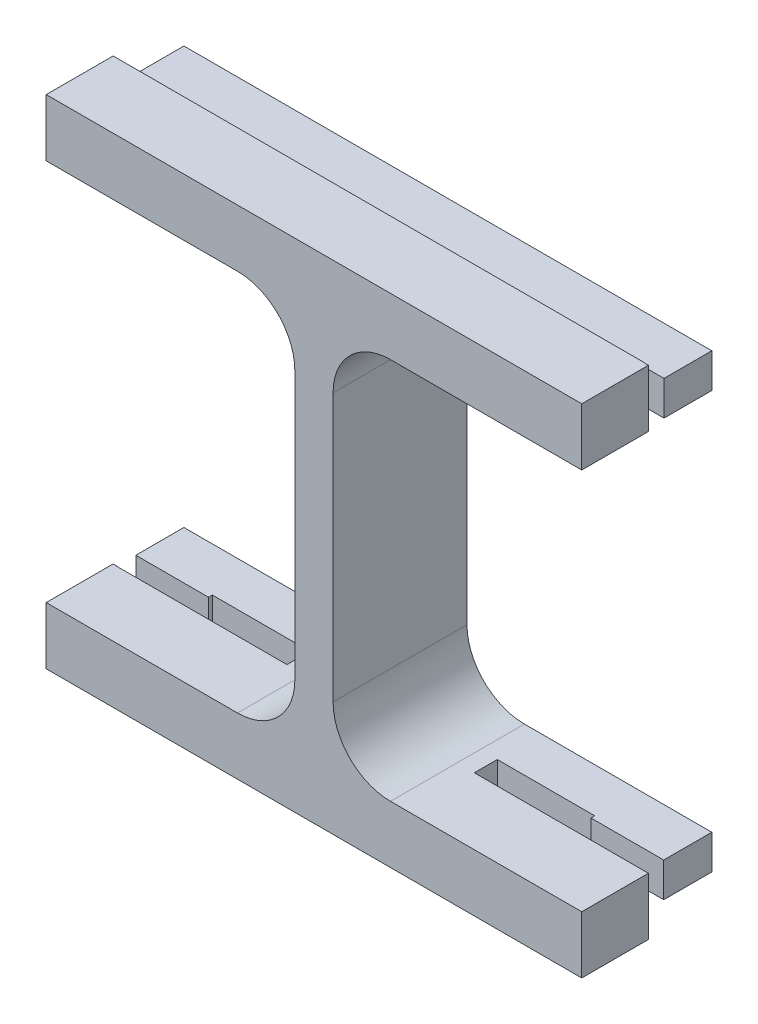
from build123d import *

# Parameters (mm, degrees)
SKETCH1_W           = 30
SKETCH1_H           = 22
BOSS_EXTRUDE1_DEPTH = 2
SKETCH2_W           = 13
SKETCH2_H           = 20
CUT_EXTRUDE1_DEPTH  = 2
FILLET1_R           = 3
SKETCH3_W           = 30
SKETCH3_H           = 22
BOSS_EXTRUDE2_DEPTH = 20
SKETCH4_W           = 30
SKETCH4_H           = 22
BOSS_EXTRUDE3_DEPTH = 2
SKETCH5_W           = 30
SKETCH5_H           = 22
BOSS_EXTRUDE4_DEPTH = 2
SKETCH6_W           = 18.015144258
SKETCH6_H           = 26
CUT_EXTRUDE2_DEPTH  = 1.2
SKETCH7_W           = 18
SKETCH7_H           = 26
CUT_EXTRUDE3_DEPTH  = 1.2
SKETCH8_W           = 27.6
SKETCH8_H           = 18
CUT_EXTRUDE4_DEPTH  = 1.2
SKETCH9_W           = 27.6
SKETCH9_H           = 18.015144258
CUT_EXTRUDE5_DEPTH  = 1.2
SKETCH10_W          = 8.9
SKETCH10_H          = 1
CUT_EXTRUDE7_DEPTH  = 1.8
SKETCH12_W          = 5.2
SKETCH12_H          = 1.2
CUT_EXTRUDE8_DEPTH  = 1.8
CUT_EXTRUDE9_DEPTH  = 3.2
SKETCH14_W          = 2.8
SKETCH14_H          = 1
CUT_EXTRUDE10_DEPTH = 5
SKETCH15_W          = 8.9
SKETCH15_H          = 1
CUT_EXTRUDE11_DEPTH = 5
SKETCH16_W          = 5.1
SKETCH16_H          = 1.2
CUT_EXTRUDE12_DEPTH = 5
SKETCH17_W          = 27.6
SKETCH17_H          = 14.5
CUT_EXTRUDE13_DEPTH = 23.6
CUT_EXTRUDE14_DEPTH = 5
SKETCH19_W          = 2.8
SKETCH19_H          = 20
CUT_EXTRUDE16_DEPTH = 3.5
SKETCH20_W          = 8.574892863
SKETCH20_H          = 20
SKETCH20_W_2        = 12.614156469
CUT_EXTRUDE18_DEPTH = 5
SKETCH24_W          = 0.5
SKETCH24_H          = 26
CUT_EXTRUDE19_DEPTH = 100
SKETCH25_W          = 4.142834468
SKETCH25_H          = 28.533772401
SKETCH25_W_2        = 4.453547053
SKETCH25_H_2        = 29.155197571
CUT_EXTRUDE20_DEPTH = 3.5


with BuildPart() as part:
    # Sketch1 → Boss-Extrude1 (new body)
    with BuildSketch(Plane.XY):
        with Locations((1.554069904, 0.785714286)):
            Rectangle(SKETCH1_W, SKETCH1_H)
    extrude(amount=BOSS_EXTRUDE1_DEPTH)

    # Sketch2 → Cut-Extrude1 (cut)
    with BuildSketch(Plane.XY.offset(2)):
        with Locations((-5.945930096, 0.785714286)):
            Rectangle(SKETCH2_W, SKETCH2_H)
        with Locations((9.054069904, 0.785714286)):
            Rectangle(SKETCH2_W, SKETCH2_H)
    extrude(amount=-CUT_EXTRUDE1_DEPTH, mode=Mode.SUBTRACT)

    # Fillet1
    fillet1_edges = [part.edges().sort_by_distance(p)[0] for p in [
        (-12.445930096, -9.214285714, 1),
        (-12.445930096, 10.785714286, 1),
        (0.554069904, 10.785714286, 1),
        (0.554069904, -9.214285714, 1),
        (15.554069904, 10.785714286, 1),
        (15.554069904, -9.214285714, 1),
        (2.554069904, -9.214285714, 1),
        (2.554069904, 10.785714286, 1),
    ]]
    fillet(fillet1_edges, radius=FILLET1_R)

    # Sketch3 → Boss-Extrude2 (add)
    with BuildSketch(Plane(origin=(0, 0, 0), x_dir=(-1, 0, 0), z_dir=(0, 0, -1))):
        with Locations((-1.554069904, 0.785714286)):
            Rectangle(SKETCH3_W, SKETCH3_H)
    extrude(amount=BOSS_EXTRUDE2_DEPTH)

    # Sketch4 → Boss-Extrude3 (add)
    with BuildSketch(Plane(origin=(0, 11.785714286, 0), x_dir=(1, 0, 0), z_dir=(0, 1, 0))):
        with Locations((1.554069904, 9)):
            Rectangle(SKETCH4_W, SKETCH4_H)
    extrude(amount=BOSS_EXTRUDE3_DEPTH)

    # Sketch5 → Boss-Extrude4 (add)
    with BuildSketch(Plane(origin=(0, -10.214285714, 0), x_dir=(-1, 0, 0), z_dir=(0, -1, 0))):
        with Locations((-1.554069904, 9)):
            Rectangle(SKETCH5_W, SKETCH5_H)
    extrude(amount=BOSS_EXTRUDE4_DEPTH)

    # Sketch6 → Cut-Extrude2 (cut)
    with BuildSketch(Plane(origin=(16.554069904, 0, 0), x_dir=(0, 0, -1), z_dir=(1, 0, 0))):
        with Locations((10.992427871, 0.785714286)):
            Rectangle(SKETCH6_W, SKETCH6_H)
    extrude(amount=-CUT_EXTRUDE2_DEPTH, mode=Mode.SUBTRACT)

    # Sketch7 → Cut-Extrude3 (cut)
    with BuildSketch(Plane.ZY.offset(13.445930096)):
        with Locations((-11, 0.785714286)):
            Rectangle(SKETCH7_W, SKETCH7_H)
    extrude(amount=-CUT_EXTRUDE3_DEPTH, mode=Mode.SUBTRACT)

    # Sketch8 → Cut-Extrude4 (cut)
    with BuildSketch(Plane(origin=(0, 13.785714286, 0), x_dir=(1, 0, 0), z_dir=(0, 1, 0))):
        with Locations((1.554069904, 11)):
            Rectangle(SKETCH8_W, SKETCH8_H)
    extrude(amount=-CUT_EXTRUDE4_DEPTH, mode=Mode.SUBTRACT)

    # Sketch9 → Cut-Extrude5 (cut)
    with BuildSketch(Plane.XZ.offset(12.214285714)):
        with Locations((1.554069904, -10.992427871)):
            Rectangle(SKETCH9_W, SKETCH9_H)
    extrude(amount=-CUT_EXTRUDE5_DEPTH, mode=Mode.SUBTRACT)

    # Sketch10 → Cut-Extrude7 (cut)
    with BuildSketch(Plane(origin=(0, 12.585714286, 0), x_dir=(1, 0, 0), z_dir=(0, 1, 0))):
        with Locations((-7.795930096, 2.5)):
            Rectangle(SKETCH10_W, SKETCH10_H)
        with Locations((10.904069904, 2.5)):
            Rectangle(SKETCH10_W, SKETCH10_H)
    extrude(amount=-CUT_EXTRUDE7_DEPTH, mode=Mode.SUBTRACT)

    # Sketch12 → Cut-Extrude8 (cut)
    with BuildSketch(Plane(origin=(0, 12.585714286, 0), x_dir=(1, 0, 0), z_dir=(0, 1, 0))):
        with Locations((-5.945930096, 2.6)):
            Rectangle(SKETCH12_W, SKETCH12_H)
        with Locations((9.054069904, 2.6)):
            Rectangle(SKETCH12_W, SKETCH12_H)
    extrude(amount=-CUT_EXTRUDE8_DEPTH, mode=Mode.SUBTRACT)

    # Sketch13 → Cut-Extrude9 (cut)
    with BuildSketch(Plane.XY):
        with BuildLine():
            Line((-9.445930096, 10.785714286), (-2.445930096, 10.785714286))
            ThreePointArc((-2.445930096, 10.785714286), (-0.324609753, 9.907034629), (0.554069904, 7.785714286))
            Line((0.554069904, 7.785714286), (0.554069904, -6.214285714))
            ThreePointArc((0.554069904, -6.214285714), (-0.324609753, -8.335606058), (-2.445930096, -9.214285714))
            Line((-2.445930096, -9.214285714), (-9.445930096, -9.214285714))
            ThreePointArc((-9.445930096, -9.214285714), (-11.56725044, -8.335606058), (-12.445930096, -6.214285714))
            Line((-12.445930096, -6.214285714), (-12.445930096, 7.785714286))
            ThreePointArc((-12.445930096, 7.785714286), (-11.56725044, 9.907034629), (-9.445930096, 10.785714286))
        make_face()
        with BuildLine():
            Line((5.554069904, 10.785714286), (12.554069904, 10.785714286))
            ThreePointArc((12.554069904, 10.785714286), (14.675390247, 9.907034629), (15.554069904, 7.785714286))
            Line((15.554069904, 7.785714286), (15.554069904, -6.214285714))
            ThreePointArc((15.554069904, -6.214285714), (14.675390247, -8.335606058), (12.554069904, -9.214285714))
            Line((12.554069904, -9.214285714), (5.554069904, -9.214285714))
            ThreePointArc((5.554069904, -9.214285714), (3.43274956, -8.335606058), (2.554069904, -6.214285714))
            Line((2.554069904, -6.214285714), (2.554069904, 7.785714286))
            ThreePointArc((2.554069904, 7.785714286), (3.43274956, 9.907034629), (5.554069904, 10.785714286))
        make_face()
    extrude(amount=-CUT_EXTRUDE9_DEPTH, mode=Mode.SUBTRACT)

    # Sketch14 → Cut-Extrude10 (cut)
    with BuildSketch(Plane(origin=(0, 10.785714286, 0), x_dir=(1, 0, 0), z_dir=(0, 1, 0))):
        with Locations((13.954069904, 2.5)):
            Rectangle(SKETCH14_W, SKETCH14_H)
        with Locations((-10.845930096, 2.5)):
            Rectangle(SKETCH14_W, SKETCH14_H)
    extrude(amount=-CUT_EXTRUDE10_DEPTH, mode=Mode.SUBTRACT)

    # Sketch15 → Cut-Extrude11 (cut)
    with BuildSketch(Plane(origin=(0, -11.014285714, 0), x_dir=(-1, 0, 0), z_dir=(0, -1, 0))):
        with Locations((7.795930096, 2.484855742)):
            Rectangle(SKETCH15_W, SKETCH15_H)
        with Locations((-10.904069904, 2.484855742)):
            Rectangle(SKETCH15_W, SKETCH15_H)
    extrude(amount=-CUT_EXTRUDE11_DEPTH, mode=Mode.SUBTRACT)

    # Sketch16 → Cut-Extrude12 (cut)
    with BuildSketch(Plane(origin=(0, -11.014285714, 0), x_dir=(-1, 0, 0), z_dir=(0, -1, 0))):
        with Locations((5.895930096, 2.584855742)):
            Rectangle(SKETCH16_W, SKETCH16_H)
        with Locations((-9.004069904, 2.584855742)):
            Rectangle(SKETCH16_W, SKETCH16_H)
    extrude(amount=-CUT_EXTRUDE12_DEPTH, mode=Mode.SUBTRACT)

    # Sketch17 → Cut-Extrude13 (cut)
    with BuildSketch(Plane(origin=(0, 12.585714286, 0), x_dir=(1, 0, 0), z_dir=(0, 1, 0))):
        with Locations((1.554069904, 12.75)):
            Rectangle(SKETCH17_W, SKETCH17_H)
    extrude(amount=-CUT_EXTRUDE13_DEPTH, mode=Mode.SUBTRACT)

    # Sketch18 → Cut-Extrude14 (cut)
    with BuildSketch(Plane.XY.offset(-3.2)):
        with BuildLine():
            Line((-12.445930096, 7.785714286), (-12.445930096, -6.214285714))
            ThreePointArc((-12.445930096, -6.214285714), (-11.56725044, -8.335606058), (-9.445930096, -9.214285714))
            Line((-9.445930096, -9.214285714), (-2.445930096, -9.214285714))
            ThreePointArc((-2.445930096, -9.214285714), (-0.324609753, -8.335606058), (0.554069904, -6.214285714))
            Line((0.554069904, -6.214285714), (0.554069904, 7.785714286))
            ThreePointArc((0.554069904, 7.785714286), (-0.324609753, 9.907034629), (-2.445930096, 10.785714286))
            Line((-2.445930096, 10.785714286), (-9.445930096, 10.785714286))
            ThreePointArc((-9.445930096, 10.785714286), (-11.56725044, 9.907034629), (-12.445930096, 7.785714286))
        make_face()
        with BuildLine():
            Line((5.554069904, 10.785714286), (12.554069904, 10.785714286))
            ThreePointArc((12.554069904, 10.785714286), (14.675390247, 9.907034629), (15.554069904, 7.785714286))
            Line((15.554069904, 7.785714286), (15.554069904, -6.214285714))
            ThreePointArc((15.554069904, -6.214285714), (14.675390247, -8.335606058), (12.554069904, -9.214285714))
            Line((12.554069904, -9.214285714), (5.554069904, -9.214285714))
            ThreePointArc((5.554069904, -9.214285714), (3.43274956, -8.335606058), (2.554069904, -6.214285714))
            Line((2.554069904, -6.214285714), (2.554069904, 7.785714286))
            ThreePointArc((2.554069904, 7.785714286), (3.43274956, 9.907034629), (5.554069904, 10.785714286))
        make_face()
    extrude(amount=-CUT_EXTRUDE14_DEPTH, mode=Mode.SUBTRACT)

    # Sketch19 → Cut-Extrude16 (cut)
    with BuildSketch(Plane(origin=(0, 0, -5.5), x_dir=(-1, 0, 0), z_dir=(0, 0, -1))):
        with Locations((-13.954069904, 0.785714286)):
            Rectangle(SKETCH19_W, SKETCH19_H)
        with Locations((10.845930096, 0.785714286)):
            Rectangle(SKETCH19_W, SKETCH19_H)
    extrude(amount=-CUT_EXTRUDE16_DEPTH, mode=Mode.SUBTRACT)

    # Sketch20 → Cut-Extrude18 (cut)
    with BuildSketch(Plane.XY.offset(2)):
        with Locations((-13.733376528, 0.785714286)):
            Rectangle(SKETCH20_W, SKETCH20_H)
        with Locations((18.861148139, 0.785714286)):
            Rectangle(SKETCH20_W_2, SKETCH20_H)
    extrude(amount=-CUT_EXTRUDE18_DEPTH, mode=Mode.SUBTRACT)

    # Sketch24 → Cut-Extrude19 (cut)
    with BuildSketch(Plane.ZY.offset(13.445930096)):
        with Locations((1.75, 0.785714286)):
            Rectangle(SKETCH24_W, SKETCH24_H)
    extrude(amount=-CUT_EXTRUDE19_DEPTH, mode=Mode.SUBTRACT)

    # Sketch25 → Cut-Extrude20 (cut)
    with BuildSketch(Plane.XY.offset(1.5)):
        with Locations((-14.51734733, 1.251783163)):
            Rectangle(SKETCH25_W, SKETCH25_H)
        with Locations((17.78084343, 0.941070578)):
            Rectangle(SKETCH25_W_2, SKETCH25_H_2)
    extrude(amount=-CUT_EXTRUDE20_DEPTH, mode=Mode.SUBTRACT)


solid = part.part
